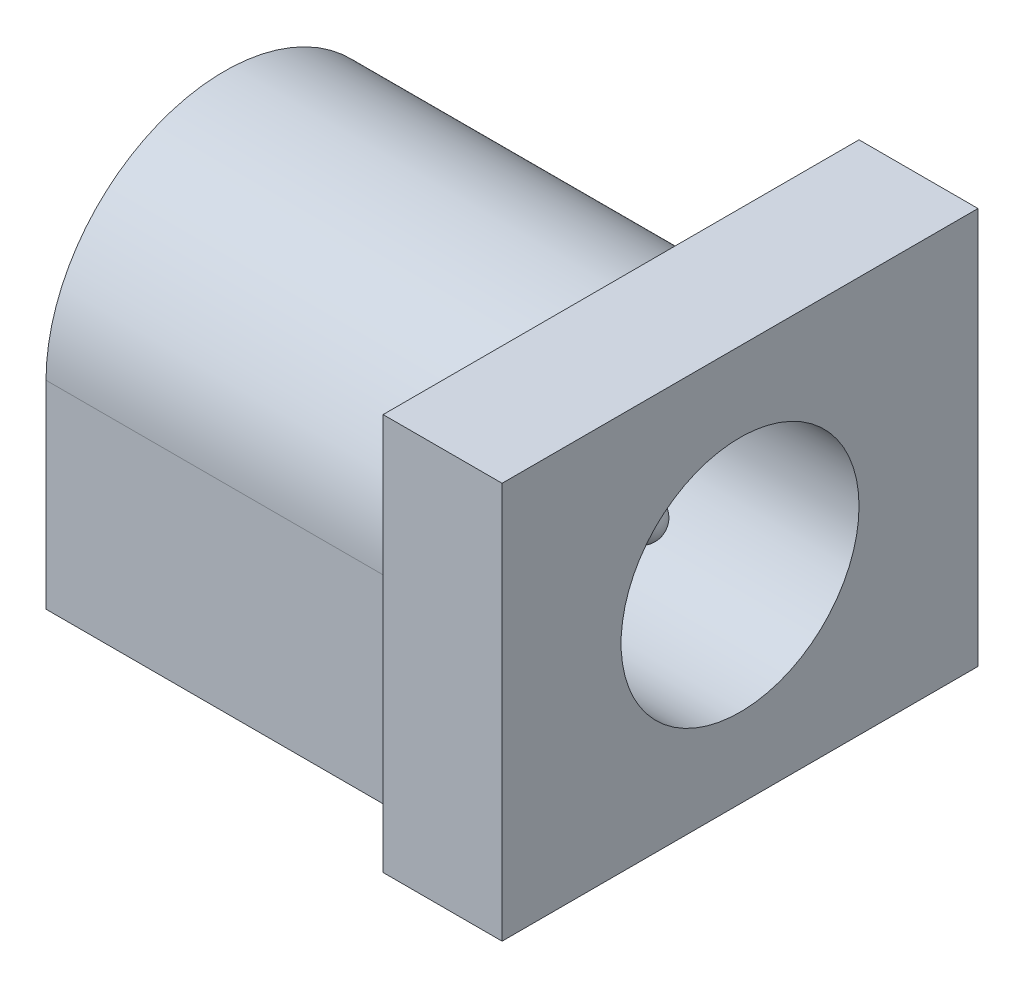
from build123d import *

# Parameters (mm, degrees)
BOSS_EXTRUDE1_DEPTH = 10
SKETCH2_W           = 12
SKETCH2_H           = 10
BOSS_EXTRUDE2_DEPTH = 3
SKETCH3_R           = 3
CUT_EXTRUDE1_DEPTH  = 12
SKETCH4_R           = 0.5
BOSS_EXTRUDE3_DEPTH = 10
FILLET1_R           = 0.5


with BuildPart() as part:
    # Sketch1 → Boss-Extrude1 (new body)
    with BuildSketch(Plane(origin=(0, 0, 0), x_dir=(0, 0, -1), z_dir=(1, 0, 0))):
        with BuildLine():
            Line((-4.5, 0), (4.5, 0))
            Line((4.5, 0), (4.5, 5))
            ThreePointArc((4.5, 5), (0, 9.5), (-4.5, 5))
            Line((-4.5, 5), (-4.5, 0))
        make_face()
    extrude(amount=BOSS_EXTRUDE1_DEPTH)

    # Sketch2 → Boss-Extrude2 (add)
    with BuildSketch(Plane(origin=(10, 0, 0), x_dir=(0, 0, -1), z_dir=(1, 0, 0))):
        with Locations((0, 5)):
            Rectangle(SKETCH2_W, SKETCH2_H)
    extrude(amount=BOSS_EXTRUDE2_DEPTH)

    # Sketch3 → Cut-Extrude1 (cut)
    with BuildSketch(Plane(origin=(13, 0, 0), x_dir=(0, 0, -1), z_dir=(1, 0, 0))):
        with Locations((0, 5)):
            Circle(SKETCH3_R)
    extrude(amount=-CUT_EXTRUDE1_DEPTH, mode=Mode.SUBTRACT)

    # Sketch4 → Boss-Extrude3 (add)
    with BuildSketch(Plane(origin=(1, 0, 0), x_dir=(0, 0, -1), z_dir=(1, 0, 0))):
        with Locations((0, 5)):
            Circle(SKETCH4_R)
    extrude(amount=BOSS_EXTRUDE3_DEPTH)

    # Fillet1
    fillet1_edges = [part.edges().sort_by_distance(p)[0] for p in [
        (11, 5, 0.5),
    ]]
    fillet(fillet1_edges, radius=FILLET1_R)


solid = part.part
